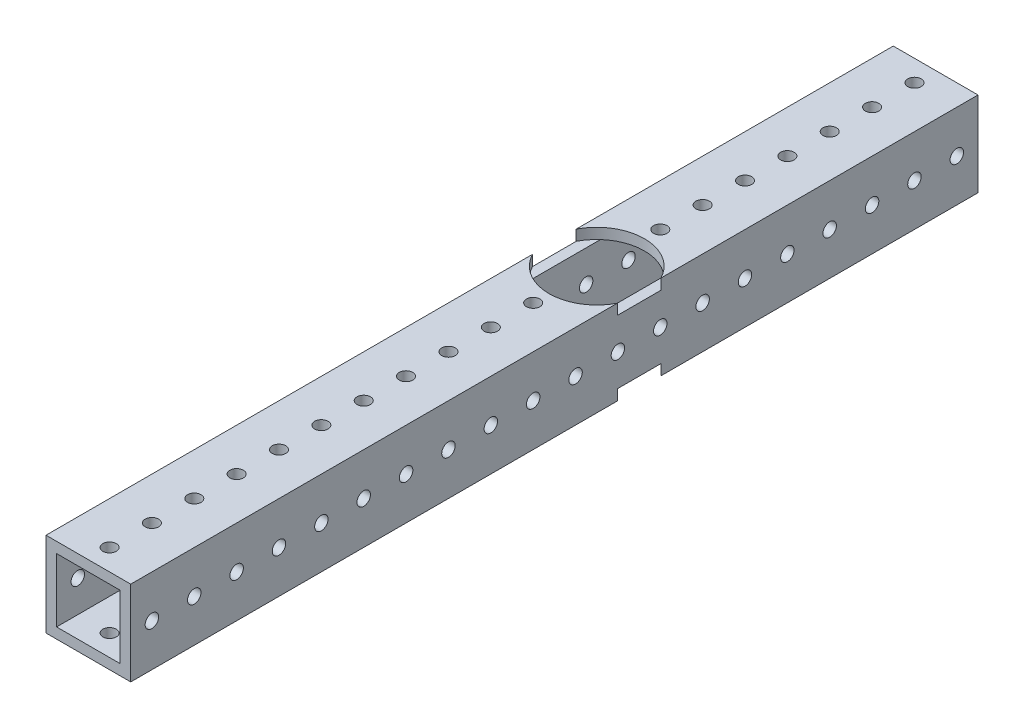
from build123d import *

# Parameters (mm, degrees)
SKETCH1_W           = 25.4
SKETCH1_H           = 25.4
SKETCH1_W_2         = 19.05
SKETCH1_H_2         = 19.05
BOSS_EXTRUDE1_DEPTH = 127
SKETCH3_R           = 2.0193
CUT_EXTRUDE1_DEPTH  = 26.4
LPATTERN1_COUNT     = 20
LPATTERN1_PITCH     = 12.7
SKETCH4_R           = 2.0193
CUT_EXTRUDE2_DEPTH  = 26.4
LPATTERN2_COUNT     = 20
LPATTERN2_PITCH     = 12.7
SKETCH8_R           = 14.2875
CUT_EXTRUDE6_DEPTH  = 3.175


with BuildPart() as part:
    # Sketch1 → Boss-Extrude1 (new body, symmetric)
    with BuildSketch(Plane.XY):
        Rectangle(SKETCH1_W, SKETCH1_H)
        Rectangle(SKETCH1_W_2, SKETCH1_H_2, mode=Mode.SUBTRACT)
    extrude(amount=BOSS_EXTRUDE1_DEPTH, both=True)

    # Sketch3 → Cut-Extrude1 (cut, through all)
    with BuildSketch(Plane(origin=(0, 12.7, 0), x_dir=(1, 0, 0), z_dir=(0, 1, 0))):
        with Locations((0, -120.65)):
            Circle(SKETCH3_R)
    cut_extrude1 = extrude(amount=-CUT_EXTRUDE1_DEPTH, mode=Mode.SUBTRACT)

    # LPattern1: Cut-Extrude1 ×20
    with Locations(*[(0, 0, -i * LPATTERN1_PITCH) for i in range(1, LPATTERN1_COUNT)]):
        add(cut_extrude1, mode=Mode.SUBTRACT)

    # Sketch4 → Cut-Extrude2 (cut, through all)
    with BuildSketch(Plane.ZY.offset(12.7)):
        with Locations((120.65, 0)):
            Circle(SKETCH4_R)
    cut_extrude2 = extrude(amount=-CUT_EXTRUDE2_DEPTH, mode=Mode.SUBTRACT)

    # LPattern2: Cut-Extrude2 ×20
    with Locations(*[(0, 0, -i * LPATTERN2_PITCH) for i in range(1, LPATTERN2_COUNT)]):
        add(cut_extrude2, mode=Mode.SUBTRACT)

    # Sketch8 → Cut-Extrude6 (cut)
    with BuildSketch(Plane(origin=(0, 12.7, 0), x_dir=(1, 0, 0), z_dir=(0, 1, 0))):
        with Locations((0, 25.4)):
            Circle(SKETCH8_R)
    cut_extrude6 = extrude(amount=-CUT_EXTRUDE6_DEPTH, mode=Mode.SUBTRACT)

    # Mirror4: Cut-Extrude6 across plane
    add(cut_extrude6.mirror(Plane.ZX), mode=Mode.SUBTRACT)


solid = part.part
